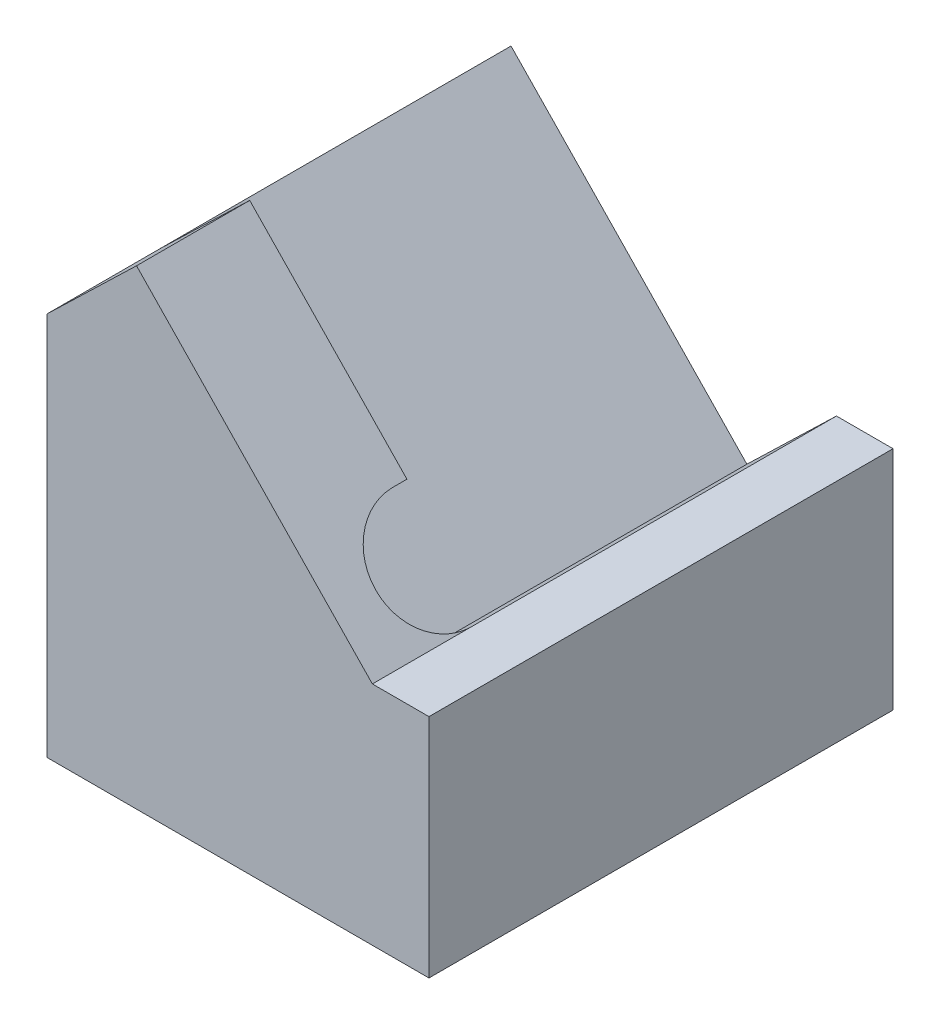
from build123d import *

# Parameters (mm, degrees)
BOSS_EXTRUDE1_DEPTH       = 8.2
CUT_EXTRUDE1_DEPTH        = 2.2
SKETCH3_W                 = 6.75
SKETCH3_H                 = 8.2
BOSS_EXTRUDE2_DEPTH       = 2
F_1_5MM_DOWEL_HOLE1_D     = 1.5
F_1_5MM_DOWEL_HOLE1_DEPTH = 3
F_1_5MM_DOWEL_HOLE1_TIP   = 0.450645464
M2X0_4_TAPPED_HOLE1_D     = 1.6
M2X0_4_TAPPED_HOLE1_DEPTH = 3
M2X0_4_TAPPED_HOLE1_TIP   = 0.480688495


with BuildPart() as part:
    # Sketch1 → Boss-Extrude1 (new body)
    with BuildSketch(Plane.XY):
        Polygon((0, 0), (0, 4.787274917), (1.582547561, 6.315523332), (5.75, 2), (6.75, 2), (6.75, 0), align=None)
    extrude(amount=BOSS_EXTRUDE1_DEPTH)

    # Sketch2 → Cut-Extrude1 (cut)
    with BuildSketch(Plane(origin=(3.97472688, 3.838349131, 0), x_dir=(0, 0, -1), z_dir=(0.7193398, 0.69465837, 0))):
        with BuildLine():
            Line((0, 3.443677383), (0, -2.555606029))
            Line((0, -2.555606029), (-6.45, -2.555606029))
            ThreePointArc((-6.45, -2.555606029), (-7.45, -1.555606029), (-6.45, -0.555606029))
            Line((-6.45, -0.555606029), (-6.2, -0.555606029))
            Line((-6.2, -0.555606029), (-6.2, 3.443677383))
            Line((-6.2, 3.443677383), (0, 3.443677383))
        make_face()
    extrude(amount=-CUT_EXTRUDE1_DEPTH, mode=Mode.SUBTRACT)

    # Sketch3 → Boss-Extrude2 (add)
    with BuildSketch(Plane.XZ):
        with Locations((3.375, 4.1)):
            Rectangle(SKETCH3_W, SKETCH3_H)
    extrude(amount=BOSS_EXTRUDE2_DEPTH)

    # Ø1.5mm Dowel Hole1
    with Locations(Plane(origin=(0, -2, 0), x_dir=(-1, 0, 0), z_dir=(0, -1, 0))):
        with Locations((-2, -7.1), (-2, -1.1)):
            Hole(F_1_5MM_DOWEL_HOLE1_D / 2, depth=F_1_5MM_DOWEL_HOLE1_DEPTH)
            with Locations((0, 0, -(F_1_5MM_DOWEL_HOLE1_DEPTH + F_1_5MM_DOWEL_HOLE1_TIP / 2))):  # 118° drill point
                Cone(0, F_1_5MM_DOWEL_HOLE1_D / 2, F_1_5MM_DOWEL_HOLE1_TIP, mode=Mode.SUBTRACT)

    # M2x0.4 Tapped Hole1
    with Locations(Plane(origin=(0, -2, 0), x_dir=(-1, 0, 0), z_dir=(0, -1, 0))):
        with Locations((-2, -4.1)):
            Hole(M2X0_4_TAPPED_HOLE1_D / 2, depth=M2X0_4_TAPPED_HOLE1_DEPTH)
            with Locations((0, 0, -(M2X0_4_TAPPED_HOLE1_DEPTH + M2X0_4_TAPPED_HOLE1_TIP / 2))):  # 118° drill point
                Cone(0, M2X0_4_TAPPED_HOLE1_D / 2, M2X0_4_TAPPED_HOLE1_TIP, mode=Mode.SUBTRACT)


solid = part.part
